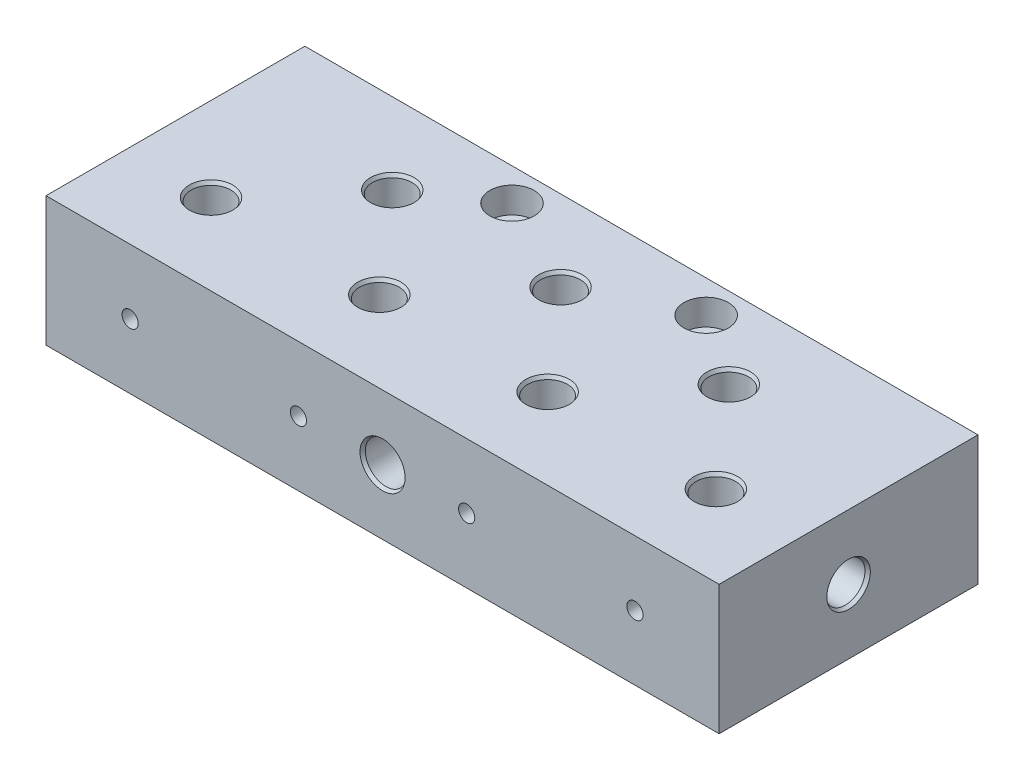
from build123d import *

# Parameters (mm, degrees)
SKETCH1_W                                       = 132.08
SKETCH1_H                                       = 50.8
BOSS_EXTRUDE1_DEPTH                             = 25.4
SKETCH2_R                                       = 3.8862
CUT_EXTRUDE1_DEPTH                              = 12.7
SKETCH3_R                                       = 1.5875
CUT_EXTRUDE2_DEPTH                              = 25.4
SKETCH5_R                                       = 1.5875
CUT_EXTRUDE4_DEPTH                              = 25.4
SKETCH6_R                                       = 1.5875
CUT_EXTRUDE5_DEPTH                              = 133.08
SKETCH7_R                                       = 3.8862
CUT_EXTRUDE6_DEPTH                              = 12.7
SKETCH8_R                                       = 3.8862
CUT_EXTRUDE7_DEPTH                              = 12.7
SKETCH9_R                                       = 1.5875
CUT_EXTRUDE8_DEPTH                              = 25.4
SKETCH10_R                                      = 4.0386
CUT_EXTRUDE9_DEPTH                              = 12.7
SKETCH11_R                                      = 3.8862
CUT_EXTRUDE10_DEPTH                             = 12.7
CBORE_FOR_10_SOCKET_HEAD_CAP_SCREW1_D           = 4.9784
CBORE_FOR_10_SOCKET_HEAD_CAP_SCREW1_DEPTH       = 17.78
CBORE_FOR_10_SOCKET_HEAD_CAP_SCREW1_CBORE_D     = 8.6868
CBORE_FOR_10_SOCKET_HEAD_CAP_SCREW1_CBORE_DEPTH = 5.08
CBORE_FOR_10_SOCKET_HEAD_CAP_SCREW1_TIP         = 1.495662253
CHAMFER1_SIZE                                   = 0.381
CHAMFER1_SIZE2                                  = 0.659911358
CHAMFER1_PART_2_SIZE                            = 0.381
CHAMFER1_PART_2_SIZE2                           = 0.659911358
CHAMFER1_PART_3_SIZE                            = 0.381
CHAMFER1_PART_3_SIZE2                           = 0.659911358
CHAMFER1_PART_4_SIZE                            = 0.381
CHAMFER1_PART_4_SIZE2                           = 0.659911358
CHAMFER1_PART_5_SIZE                            = 0.381
CHAMFER1_PART_5_SIZE2                           = 0.659911358


with BuildPart() as part:
    # Sketch1 → Boss-Extrude1 (new body)
    with BuildSketch(Plane(origin=(0, 0, 0), x_dir=(1, 0, 0), z_dir=(0, 1, 0))):
        with Locations((66.04, 25.4)):
            Rectangle(SKETCH1_W, SKETCH1_H)
    extrude(amount=BOSS_EXTRUDE1_DEPTH)

    # Sketch2 → Cut-Extrude1 (cut)
    with BuildSketch(Plane(origin=(0, 25.4, 0), x_dir=(1, 0, 0), z_dir=(0, 1, 0))):
        with Locations((66.04, 34.925)):
            Circle(SKETCH2_R)
        with Locations((99.06, 34.925)):
            Circle(SKETCH2_R)
        with Locations((33.02, 34.925)):
            Circle(SKETCH2_R)
        with Locations((49.53, 15.875)):
            Circle(SKETCH2_R)
        with Locations((82.55, 15.875)):
            Circle(SKETCH2_R)
        with Locations((115.57, 15.875)):
            Circle(SKETCH2_R)
        with Locations((16.51, 15.875)):
            Circle(SKETCH2_R)
    extrude(amount=-CUT_EXTRUDE1_DEPTH, mode=Mode.SUBTRACT)

    # Sketch3 → Cut-Extrude2 (cut)
    with BuildSketch(Plane.XY):
        with Locations((16.51, 12.7)):
            Circle(SKETCH3_R)
        with Locations((49.53, 12.7)):
            Circle(SKETCH3_R)
        with Locations((82.55, 12.7)):
            Circle(SKETCH3_R)
        with Locations((115.57, 12.7)):
            Circle(SKETCH3_R)
    extrude(amount=-CUT_EXTRUDE2_DEPTH, mode=Mode.SUBTRACT)

    # Sketch5 → Cut-Extrude4 (cut)
    with BuildSketch(Plane(origin=(0, 0, -50.8), x_dir=(-1, 0, 0), z_dir=(0, 0, -1))):
        with Locations((-99.06, 12.7)):
            Circle(SKETCH5_R)
        with Locations((-66.04, 12.7)):
            Circle(SKETCH5_R)
        with Locations((-33.02, 12.7)):
            Circle(SKETCH5_R)
    extrude(amount=-CUT_EXTRUDE4_DEPTH, mode=Mode.SUBTRACT)

    # Sketch6 → Cut-Extrude5 (cut, through all)
    with BuildSketch(Plane(origin=(132.08, 0, 0), x_dir=(0, 0, -1), z_dir=(1, 0, 0))):
        with Locations((25.4, 12.7)):
            Circle(SKETCH6_R)
    extrude(amount=-CUT_EXTRUDE5_DEPTH, mode=Mode.SUBTRACT)

    # Sketch7 → Cut-Extrude6 (cut)
    with BuildSketch(Plane(origin=(132.08, 0, 0), x_dir=(0, 0, -1), z_dir=(1, 0, 0))):
        with Locations((25.4, 12.7)):
            Circle(SKETCH7_R)
    extrude(amount=-CUT_EXTRUDE6_DEPTH, mode=Mode.SUBTRACT)

    # Sketch8 → Cut-Extrude7 (cut)
    with BuildSketch(Plane.ZY):
        with Locations((-25.4, 12.7)):
            Circle(SKETCH8_R)
    extrude(amount=-CUT_EXTRUDE7_DEPTH, mode=Mode.SUBTRACT)

    # Sketch9 → Cut-Extrude8 (cut)
    with BuildSketch(Plane.XY):
        with Locations((66.04, 12.7)):
            Circle(SKETCH9_R)
    extrude(amount=-CUT_EXTRUDE8_DEPTH, mode=Mode.SUBTRACT)

    # Sketch10 → Cut-Extrude9 (cut)
    with BuildSketch(Plane.XY):
        with Locations((66.04, 12.7)):
            Circle(SKETCH10_R)
    extrude(amount=-CUT_EXTRUDE9_DEPTH, mode=Mode.SUBTRACT)

    # Sketch11 → Cut-Extrude10 (cut)
    with BuildSketch(Plane.XZ):
        with Locations((66.04, -25.4)):
            Circle(SKETCH11_R)
    extrude(amount=-CUT_EXTRUDE10_DEPTH, mode=Mode.SUBTRACT)

    # CBORE for #10 Socket Head Cap Screw1
    with Locations(Plane(origin=(0, 25.4, 0), x_dir=(1, 0, 0), z_dir=(0, 1, 0))):
        with Locations((46.99, 44.45), (85.09, 44.45)):
            CounterBoreHole(CBORE_FOR_10_SOCKET_HEAD_CAP_SCREW1_D / 2, CBORE_FOR_10_SOCKET_HEAD_CAP_SCREW1_CBORE_D / 2, CBORE_FOR_10_SOCKET_HEAD_CAP_SCREW1_CBORE_DEPTH, depth=CBORE_FOR_10_SOCKET_HEAD_CAP_SCREW1_DEPTH)
            with Locations((0, 0, -(CBORE_FOR_10_SOCKET_HEAD_CAP_SCREW1_DEPTH + CBORE_FOR_10_SOCKET_HEAD_CAP_SCREW1_TIP / 2))):  # 118° drill point
                Cone(0, CBORE_FOR_10_SOCKET_HEAD_CAP_SCREW1_D / 2, CBORE_FOR_10_SOCKET_HEAD_CAP_SCREW1_TIP, mode=Mode.SUBTRACT)

    # Chamfer1
    chamfer1_edges = [part.edges().sort_by_distance(p)[0] for p in [
        (132.08, 12.7, -21.5138),
    ]]
    chamfer1_side = [part.faces().sort_by_distance(p)[0] for p in [
        (132.08, 12.7, -0.567961266),
    ]]
    chamfer(chamfer1_edges, length=CHAMFER1_SIZE, length2=CHAMFER1_SIZE2, reference=chamfer1_side[0])

    # Chamfer1 part 2
    chamfer1_part_2_edges = [part.edges().sort_by_distance(p)[0] for p in [
        (0, 12.7, -29.2862),
    ]]
    chamfer1_part_2_side = [part.faces().sort_by_distance(p)[0] for p in [
        (0, 12.7, -50.232038734),
    ]]
    chamfer(chamfer1_part_2_edges, length=CHAMFER1_PART_2_SIZE, length2=CHAMFER1_PART_2_SIZE2, reference=chamfer1_part_2_side[0])

    # Chamfer1 part 3
    chamfer1_part_3_edges = [part.edges().sort_by_distance(p)[0] for p in [
        (62.1538, 25.4, -34.925),
        (78.6638, 25.4, -15.875),
        (111.6838, 25.4, -15.875),
        (12.6238, 25.4, -15.875),
        (45.6438, 25.4, -15.875),
        (29.1338, 25.4, -34.925),
        (95.1738, 25.4, -34.925),
    ]]
    chamfer1_part_3_side = [part.faces().sort_by_distance(p)[0] for p in [
        (66.04, 25.4, -25.111434935),
    ]]
    chamfer(chamfer1_part_3_edges, length=CHAMFER1_PART_3_SIZE, length2=CHAMFER1_PART_3_SIZE2, reference=chamfer1_part_3_side[0])

    # Chamfer1 part 4
    chamfer1_part_4_edges = [part.edges().sort_by_distance(p)[0] for p in [
        (62.0014, 12.7, 0),
    ]]
    chamfer1_part_4_side = [part.faces().sort_by_distance(p)[0] for p in [
        (1.345001353, 12.7, 0),
    ]]
    chamfer(chamfer1_part_4_edges, length=CHAMFER1_PART_4_SIZE, length2=CHAMFER1_PART_4_SIZE2, reference=chamfer1_part_4_side[0])

    # Chamfer1 part 5
    chamfer1_part_5_edges = [part.edges().sort_by_distance(p)[0] for p in [
        (62.1538, 0, -25.4),
    ]]
    chamfer1_part_5_side = [part.faces().sort_by_distance(p)[0] for p in [
        (66.04, 0, -1.415124249),
    ]]
    chamfer(chamfer1_part_5_edges, length=CHAMFER1_PART_5_SIZE, length2=CHAMFER1_PART_5_SIZE2, reference=chamfer1_part_5_side[0])


solid = part.part
